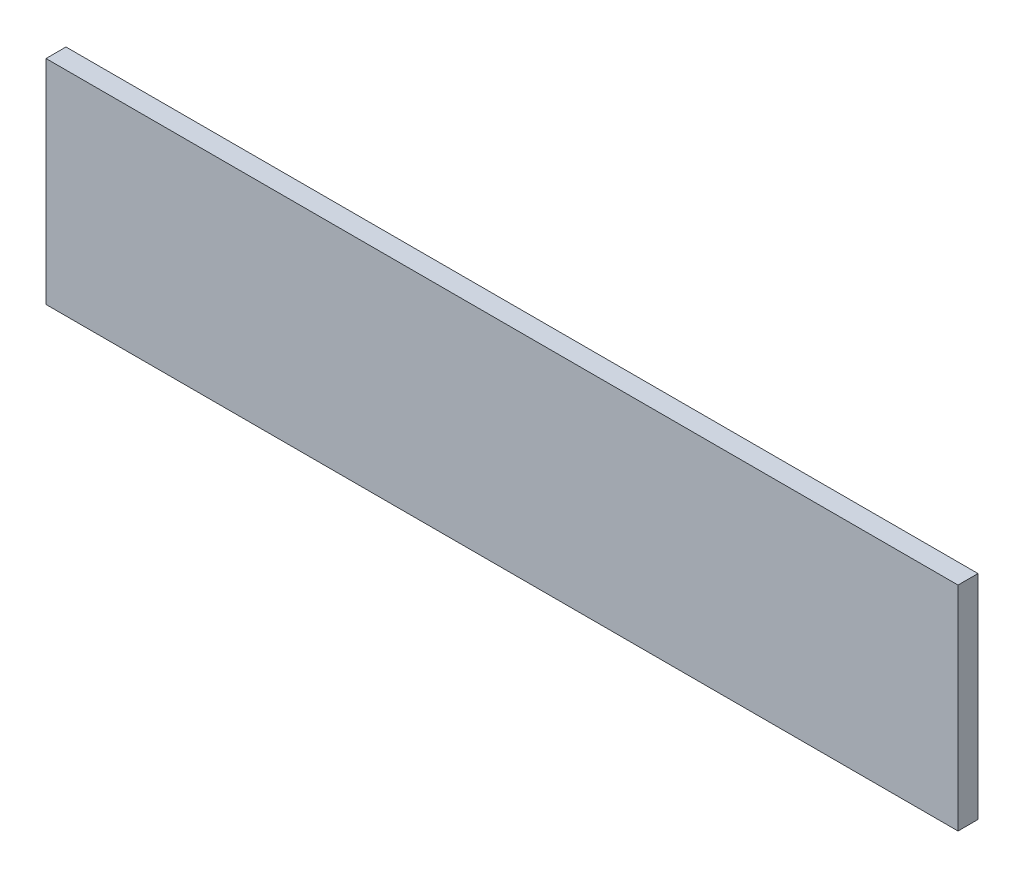
from build123d import *

# Parameters (mm, degrees)
SKETCH1_W           = 869.95
SKETCH1_H           = 203.2
BOSS_EXTRUDE1_DEPTH = 19.05


with BuildPart() as part:
    # Sketch1 → Boss-Extrude1 (new body)
    with BuildSketch(Plane.XY):
        Rectangle(SKETCH1_W, SKETCH1_H)
    extrude(amount=BOSS_EXTRUDE1_DEPTH)


solid = part.part
